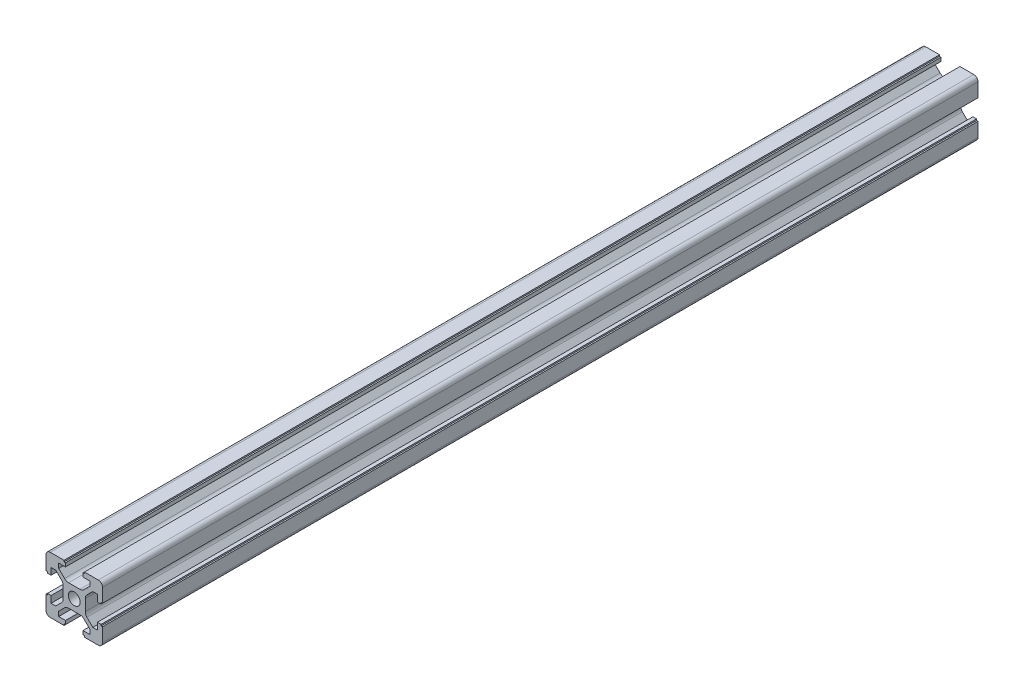
from build123d import *

# Parameters (mm, degrees)
SKETCH_1_R      = 2.1
EXTRUDE_1_DEPTH = 155


with BuildPart() as part:
    # 草图1 → 凸台-拉伸1 (new body, symmetric)
    with BuildSketch(Plane.XY):
        with BuildLine():
            Line((-3.425126266, 4.485786438), (-5.5, 6.560660172))
            Line((-5.5, 6.560660172), (-5.5, 8.2))
            Line((-5.5, 8.2), (-3.1, 8.2))
            Line((-3.1, 8.2), (-3.1, 9.5))
            Line((-3.1, 9.5), (-3.6, 9.5))
            Line((-3.6, 9.5), (-3.6, 10))
            Line((-3.6, 10), (-8.5, 10))
            ThreePointArc((-8.5, 10), (-9.560660172, 9.560660172), (-10, 8.5))
            Line((-10, 8.5), (-10, 3.6))
            Line((-10, 3.6), (-9.5, 3.6))
            Line((-9.5, 3.6), (-9.5, 3.1))
            Line((-9.5, 3.1), (-8.2, 3.1))
            Line((-8.2, 3.1), (-8.2, 5.5))
            Line((-8.2, 5.5), (-6.560660172, 5.5))
            Line((-6.560660172, 5.5), (-4.485786438, 3.425126266))
            ThreePointArc((-4.485786438, 3.425126266), (-4.052240935, 2.776279568), (-3.9, 2.010912703))
            Line((-3.9, 2.010912703), (-3.9, -2.010912703))
            ThreePointArc((-3.9, -2.010912703), (-4.052240935, -2.776279568), (-4.485786438, -3.425126266))
            Line((-4.485786438, -3.425126266), (-6.560660172, -5.5))
            Line((-6.560660172, -5.5), (-8.2, -5.5))
            Line((-8.2, -5.5), (-8.2, -3.1))
            Line((-8.2, -3.1), (-9.5, -3.1))
            Line((-9.5, -3.1), (-9.5, -3.6))
            Line((-9.5, -3.6), (-10, -3.6))
            Line((-10, -3.6), (-10, -8.5))
            ThreePointArc((-10, -8.5), (-9.560660172, -9.560660172), (-8.5, -10))
            Line((-8.5, -10), (-3.6, -10))
            Line((-3.6, -10), (-3.6, -9.5))
            Line((-3.6, -9.5), (-3.1, -9.5))
            Line((-3.1, -9.5), (-3.1, -8.2))
            Line((-3.1, -8.2), (-5.5, -8.2))
            Line((-5.5, -8.2), (-5.5, -6.560660172))
            Line((-5.5, -6.560660172), (-3.425126266, -4.485786438))
            ThreePointArc((-3.425126266, -4.485786438), (-2.776279568, -4.052240935), (-2.010912703, -3.9))
            Line((-2.010912703, -3.9), (2.010912703, -3.9))
            ThreePointArc((2.010912703, -3.9), (2.776279568, -4.052240935), (3.425126266, -4.485786438))
            Line((3.425126266, -4.485786438), (5.5, -6.560660172))
            Line((5.5, -6.560660172), (5.5, -8.2))
            Line((5.5, -8.2), (3.1, -8.2))
            Line((3.1, -8.2), (3.1, -9.5))
            Line((3.1, -9.5), (3.6, -9.5))
            Line((3.6, -9.5), (3.6, -10))
            Line((3.6, -10), (8.5, -10))
            ThreePointArc((8.5, -10), (9.560660172, -9.560660172), (10, -8.5))
            Line((10, -8.5), (10, -3.6))
            Line((10, -3.6), (9.5, -3.6))
            Line((9.5, -3.6), (9.5, -3.1))
            Line((9.5, -3.1), (8.2, -3.1))
            Line((8.2, -3.1), (8.2, -5.5))
            Line((8.2, -5.5), (6.560660172, -5.5))
            Line((6.560660172, -5.5), (4.485786438, -3.425126266))
            ThreePointArc((4.485786438, -3.425126266), (4.052240935, -2.776279568), (3.9, -2.010912703))
            Line((3.9, -2.010912703), (3.9, 2.010912703))
            ThreePointArc((3.9, 2.010912703), (4.052240935, 2.776279568), (4.485786438, 3.425126266))
            Line((4.485786438, 3.425126266), (6.560660172, 5.5))
            Line((6.560660172, 5.5), (8.2, 5.5))
            Line((8.2, 5.5), (8.2, 3.1))
            Line((8.2, 3.1), (9.5, 3.1))
            Line((9.5, 3.1), (9.5, 3.6))
            Line((9.5, 3.6), (10, 3.6))
            Line((10, 3.6), (10, 8.5))
            ThreePointArc((10, 8.5), (9.560660172, 9.560660172), (8.5, 10))
            Line((8.5, 10), (3.6, 10))
            Line((3.6, 10), (3.6, 9.5))
            Line((3.6, 9.5), (3.1, 9.5))
            Line((3.1, 9.5), (3.1, 8.2))
            Line((3.1, 8.2), (5.5, 8.2))
            Line((5.5, 8.2), (5.5, 6.560660172))
            Line((5.5, 6.560660172), (3.425126266, 4.485786438))
            ThreePointArc((3.425126266, 4.485786438), (2.776279568, 4.052240935), (2.010912703, 3.9))
            Line((2.010912703, 3.9), (-2.010912703, 3.9))
            ThreePointArc((-2.010912703, 3.9), (-2.776279568, 4.052240935), (-3.425126266, 4.485786438))
        make_face()
        Circle(SKETCH_1_R, mode=Mode.SUBTRACT)
    extrude(amount=EXTRUDE_1_DEPTH, both=True)


solid = part.part
